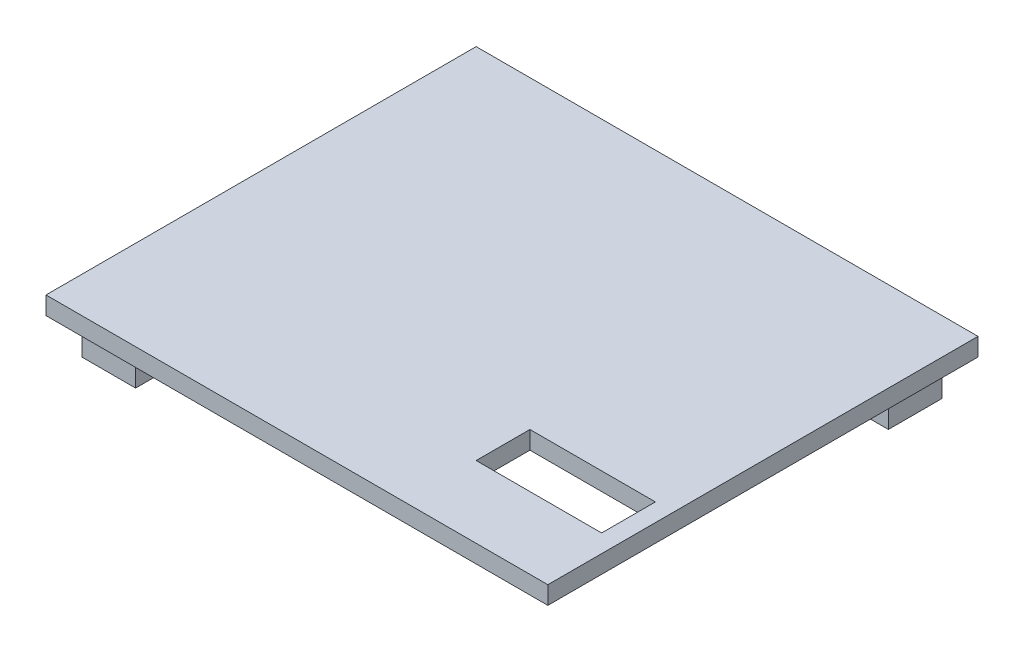
from build123d import *

# Parameters (mm, degrees)
SKETCH1_W           = 177.8
SKETCH1_H           = 152.4
SKETCH1_W_2         = 44.45
SKETCH1_H_2         = 19.05
BOSS_EXTRUDE1_DEPTH = 6.35
BOSS_EXTRUDE2_DEPTH = 12.7


with BuildPart() as part:
    # Sketch1 → Boss-Extrude1 (new body)
    with BuildSketch(Plane(origin=(0, 0, 0), x_dir=(1, 0, 0), z_dir=(0, 1, 0))):
        with Locations((-88.9, 76.2)):
            Rectangle(SKETCH1_W, SKETCH1_H)
        with Locations((-28.575, 34.925)):
            Rectangle(SKETCH1_W_2, SKETCH1_H_2, mode=Mode.SUBTRACT)
    extrude(amount=BOSS_EXTRUDE1_DEPTH)

    # Sketch2 → Boss-Extrude2 (add)
    with BuildSketch(Plane.XZ):
        Polygon((-171.45, -146.05), (-171.45, -127), (-165.1, -127), (-165.1, -139.720102982), (-152.4, -139.720102982), (-152.4, -146.05), align=None)
        Polygon((-6.35, -146.05), (-25.4, -146.05), (-25.4, -139.720102982), (-12.7, -139.720102982), (-12.7, -127), (-6.35, -127), align=None)
        Polygon((-171.45, -6.35), (-152.4, -6.35), (-152.4, -12.7), (-165.1, -12.7), (-165.1, -25.4), (-171.45, -25.4), align=None)
    extrude(amount=BOSS_EXTRUDE2_DEPTH)


solid = part.part
